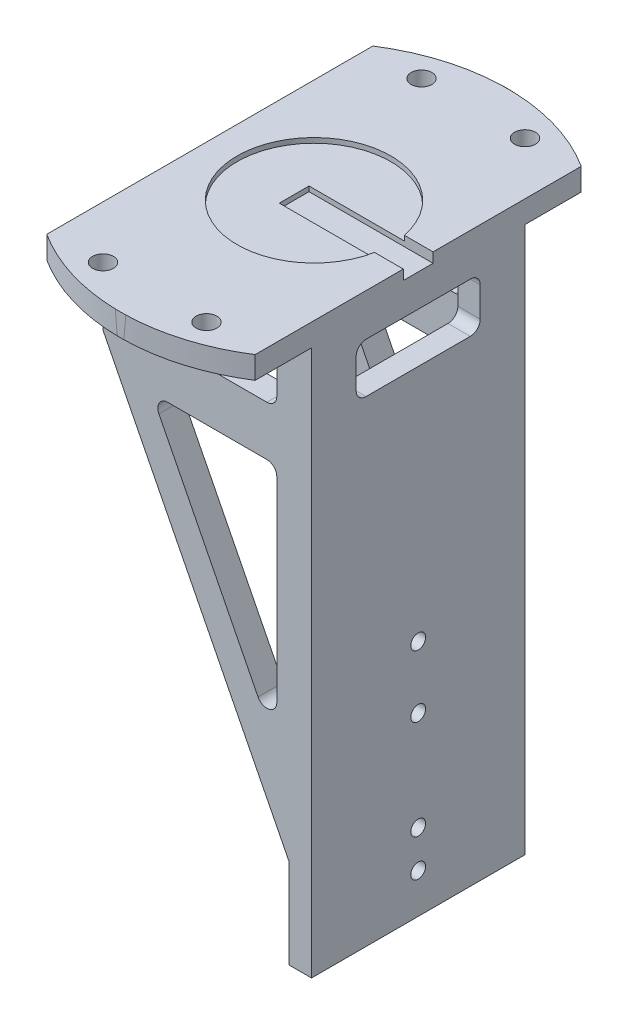
from build123d import *

# Parameters (mm, degrees)
BOSS_EXTRUDE1_DEPTH     = 80
SKETCH2_W               = 33
SKETCH2_H               = 110
CUT_EXTRUDE2_DEPTH      = 37.5
CUT_EXTRUDE6_DEPTH      = 55.5
SKETCH7_R               = 1.5000015
SKETCH7_R_2             = 1.499999754
SKETCH7_R_3             = 1.499999424
SKETCH7_R_4             = 1.499998917
CUT_EXTRUDE8_DEPTH      = 43
CUT_EXTRUDE8_DEPTH_BACK = 55.5
CUT_EXTRUDE9_DEPTH      = 110.5
CUT_EXTRUDE10_DEPTH     = 196.5
SKETCH11_R              = 2.10000039
SKETCH11_R_2            = 2.100000448
SKETCH11_R_3            = 2.1000011
SKETCH11_R_4            = 2.099999964
CUT_EXTRUDE11_DEPTH     = 196.5
CUT_EXTRUDE12_START     = 114.5
SKETCH12_R              = 15.500000658
CUT_EXTRUDE12_DEPTH     = 1
CUT_EXTRUDE13_START     = 114.5
SKETCH13_W              = 25
SKETCH13_H              = 6
CUT_EXTRUDE13_DEPTH     = 2


with BuildPart() as part:
    # Sketch1 → Boss-Extrude1 (new body)
    with BuildSketch(Plane.XY):
        Polygon((0, 114.5), (42, 114.5), (42, 0), (37.5, 0), (37.5, 18), (0, 92), align=None)
    extrude(amount=BOSS_EXTRUDE1_DEPTH)

    # Sketch2 → Cut-Extrude2 (cut)
    with BuildSketch(Plane(origin=(0, 0, 0), x_dir=(0, 0, -1), z_dir=(1, 0, 0))):
        with Locations((-39, 55)):
            Rectangle(SKETCH2_W, SKETCH2_H)
    extrude(amount=CUT_EXTRUDE2_DEPTH, mode=Mode.SUBTRACT)

    # Sketch6 → Cut-Extrude6 (cut)
    with BuildSketch(Plane(origin=(0, 0, 0), x_dir=(0, 0, -1), z_dir=(1, 0, 0))):
        Polygon((-17.5, 110), (-0.011922265, 110), (-0.011922265, 114.499832966), (14.004945748, 114.499832966), (14.004945748, 0), (-17.5, 0), align=None)
        Polygon((-60.5, 110), (-77.994888003, 110), (-77.985702515, 114.5), (-108.593167203, 114.5), (-108.593167203, 0), (-60.5, 0), align=None)
    extrude(amount=CUT_EXTRUDE6_DEPTH, mode=Mode.SUBTRACT)

    # Sketch7 → Cut-Extrude8 (cut, two sides)
    with BuildSketch(Plane(origin=(0, 0, 0), x_dir=(0, 0, -1), z_dir=(1, 0, 0))) as cut_extrude8_sk:
        with Locations((-39.000000948, 47.999997685)):
            Circle(SKETCH7_R)
        with Locations((-39, 35.499996297)):
            Circle(SKETCH7_R_2)
        with Locations((-39.000001283, 8.000001659)):
            Circle(SKETCH7_R_3)
        with Locations((-39.000000539, 15.500000933)):
            Circle(SKETCH7_R_4)
        with BuildLine():
            Line((-49.5, 106), (-28.187131882, 105.975372314))
            ThreePointArc((-28.187131882, 105.975372314), (-26.979186724, 105.298896246), (-26.5, 104))
            Line((-26.5, 104), (-26.5, 98))
            ThreePointArc((-26.5, 98), (-27.085785866, 96.585785866), (-28.5, 96))
            Line((-28.5, 96), (-49.5, 96))
            ThreePointArc((-49.5, 96), (-50.914215088, 96.585784912), (-51.5, 98))
            Line((-51.5, 98), (-51.5, 104))
            ThreePointArc((-51.5, 104), (-50.914215088, 105.414215088), (-49.5, 106))
        make_face()
    extrude(amount=CUT_EXTRUDE8_DEPTH, mode=Mode.SUBTRACT)
    extrude(cut_extrude8_sk.sketch, amount=-CUT_EXTRUDE8_DEPTH_BACK, mode=Mode.SUBTRACT)

    # Sketch8 → Cut-Extrude9 (cut)
    with BuildSketch(Plane.XY):
        with BuildLine():
            Line((33, 86), (13.022629738, 86))
            ThreePointArc((13.022629738, 86), (11.318500031, 85.046870918), (11.238623619, 83.095939636))
            Line((11.238623619, 83.095939636), (31.215991974, 43.673931122))
            ThreePointArc((31.215991974, 43.673931122), (33.464748466, 42.632740588), (35, 44.577987671))
            Line((35, 44.577987671), (35, 84))
            ThreePointArc((35, 84), (34.414214051, 85.414214051), (33, 86))
        make_face()
        with BuildLine():
            Line((9, 106), (33, 106))
            ThreePointArc((33, 106), (34.414214051, 105.414214051), (35, 104))
            Line((35, 104), (35, 98))
            ThreePointArc((35, 98), (34.414214051, 96.585785949), (33, 96))
            Line((33, 96), (9, 96))
            ThreePointArc((9, 96), (7.585785856, 96.585786135), (6.999999046, 98))
            Line((6.999999046, 98), (6.999999046, 104))
            ThreePointArc((6.999999046, 104), (7.585785772, 105.414213949), (9, 106))
        make_face()
    extrude(amount=CUT_EXTRUDE9_DEPTH, mode=Mode.SUBTRACT)

    # Sketch10 → Cut-Extrude10 (cut)
    with BuildSketch(Plane(origin=(0, 0, 0), x_dir=(1, 0, 0), z_dir=(0, 1, 0))):
        with BuildLine():
            Line((0, -6.136648178), (0, 15.4695464))
            Line((0, 15.4695464), (11.339564335, 15.4695464))
            Line((11.339564335, 15.4695464), (42, 15.4695464))
            Line((42, 15.4695464), (42, -6.136648178))
            ThreePointArc((42, -6.136648178), (21, -2.155e-06), (0, -6.136648178))
        make_face()
        with BuildLine():
            Line((0, -71.863349915), (0, -99.275377961))
            Line((0, -99.275377961), (42, -99.275377961))
            Line((42, -99.275377961), (42, -71.863349915))
            ThreePointArc((42, -71.863349915), (21, -78.000003087), (0, -71.863349915))
        make_face()
    extrude(amount=CUT_EXTRUDE10_DEPTH, mode=Mode.SUBTRACT)

    # Sketch11 → Cut-Extrude11 (cut)
    with BuildSketch(Plane(origin=(0, 0, 0), x_dir=(1, 0, 0), z_dir=(0, 1, 0))):
        with Locations((10.570675656, -6.901843556)):
            Circle(SKETCH11_R)
        with Locations((31.429323256, -6.901843615)):
            Circle(SKETCH11_R_2)
        with Locations((31.429323915, -71.098157164)):
            Circle(SKETCH11_R_3)
        with Locations((10.570676027, -71.098155911)):
            Circle(SKETCH11_R_4)
    extrude(amount=CUT_EXTRUDE11_DEPTH, mode=Mode.SUBTRACT)

    # Sketch12 → Cut-Extrude12 (cut)
    with BuildSketch(Plane(origin=(0, 0, 0), x_dir=(1, 0, 0), z_dir=(0, 1, 0)).offset(CUT_EXTRUDE12_START)):
        with Locations((20.999998985, -39.000002134)):
            Circle(SKETCH12_R)
    extrude(amount=-CUT_EXTRUDE12_DEPTH, mode=Mode.SUBTRACT)

    # Sketch13 → Cut-Extrude13 (cut)
    with BuildSketch(Plane(origin=(0, 0, 0), x_dir=(1, 0, 0), z_dir=(0, 1, 0)).offset(CUT_EXTRUDE13_START)):
        with Locations((29.5, -39)):
            Rectangle(SKETCH13_W, SKETCH13_H)
    extrude(amount=-CUT_EXTRUDE13_DEPTH, mode=Mode.SUBTRACT)


solid = part.part
